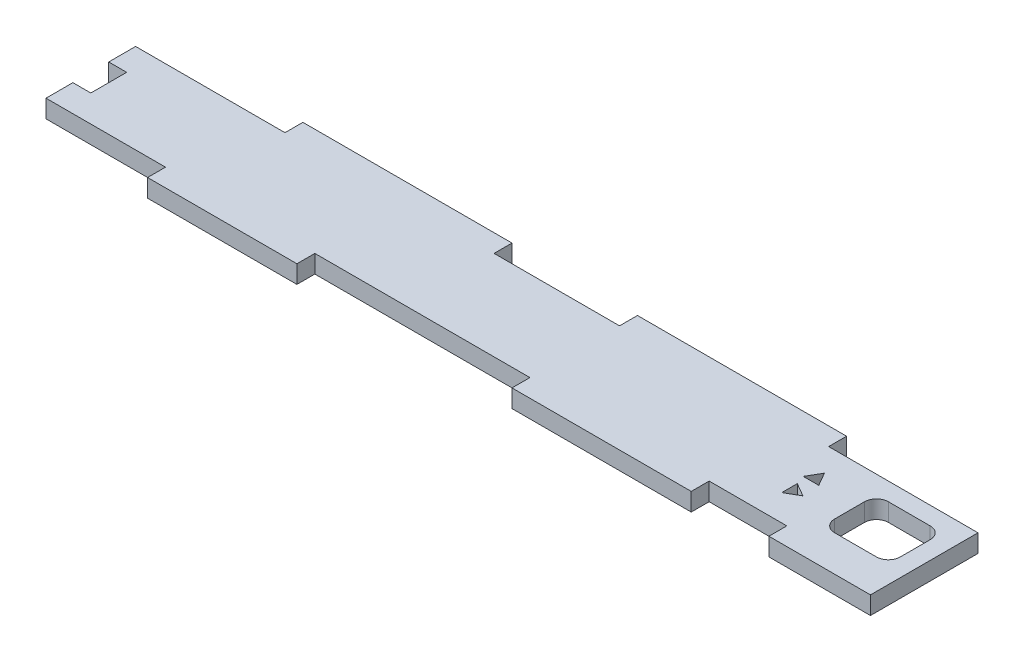
from build123d import *

# Parameters (mm, degrees)
SKETCH1_W                = 141
SKETCH1_H                = 15
BOSS_EXTRUDE1_DEPTH      = 1.5
SKETCH2_W                = 30
SKETCH2_H                = 3
SKETCH2_W_2              = 17
BOSS_EXTRUDE2_DEPTH      = 1.5
SKETCH12_W               = 25
SKETCH12_H               = 3
BOSS_EXTRUDE3_DEPTH      = 1.5
SKETCH13_W               = 35
SKETCH13_H               = 3
BOSS_EXTRUDE4_DEPTH      = 1.5
SKETCH15_W               = 11
SKETCH15_H               = 9
CUT_EXTRUDE10_DEPTH      = 2.5
CUT_EXTRUDE10_DEPTH_BACK = 2.5
FILLET4_R                = 2
CUT_EXTRUDE11_DEPTH      = 2.5
CUT_EXTRUDE11_DEPTH_BACK = 2.5
SKETCH17_W               = 3
SKETCH17_H               = 6
CUT_EXTRUDE12_DEPTH      = 2.5
CUT_EXTRUDE12_DEPTH_BACK = 2.5


with BuildPart() as part:
    # Sketch1 → Boss-Extrude1 (new body, symmetric)
    with BuildSketch(Plane(origin=(0, 0, 0), x_dir=(1, 0, 0), z_dir=(0, 1, 0))):
        Rectangle(SKETCH1_W, SKETCH1_H)
    extrude(amount=BOSS_EXTRUDE1_DEPTH, both=True)

    # Sketch2 → Boss-Extrude2 (add, symmetric)
    with BuildSketch(Plane(origin=(0, 0, 0), x_dir=(1, 0, 0), z_dir=(0, 1, 0))):
        with Locations((25.5, -9)):
            Rectangle(SKETCH2_W, SKETCH2_H)
        with Locations((62, -9)):
            Rectangle(SKETCH2_W_2, SKETCH2_H)
    extrude(amount=BOSS_EXTRUDE2_DEPTH, both=True)

    # Sketch12 → Boss-Extrude3 (add, symmetric)
    with BuildSketch(Plane(origin=(0, 0, 0), x_dir=(1, 0, 0), z_dir=(0, 1, 0))):
        with Locations((-38, -9)):
            Rectangle(SKETCH12_W, SKETCH12_H)
    extrude(amount=BOSS_EXTRUDE3_DEPTH, both=True)

    # Sketch13 → Boss-Extrude4 (add, symmetric)
    with BuildSketch(Plane(origin=(0, 0, 0), x_dir=(1, 0, 0), z_dir=(0, 1, 0))):
        with Locations((-28, 9)):
            Rectangle(SKETCH13_W, SKETCH13_H)
        with Locations((28, 9)):
            Rectangle(SKETCH13_W, SKETCH13_H)
    extrude(amount=BOSS_EXTRUDE4_DEPTH, both=True)

    # Sketch15 → Cut-Extrude10 (cut, two sides)
    with BuildSketch(Plane(origin=(0, 0, 0), x_dir=(1, 0, 0), z_dir=(0, 1, 0))) as cut_extrude10_sk:
        with Locations((62, 0)):
            Rectangle(SKETCH15_W, SKETCH15_H)
    extrude(amount=CUT_EXTRUDE10_DEPTH, mode=Mode.SUBTRACT)
    extrude(cut_extrude10_sk.sketch, amount=-CUT_EXTRUDE10_DEPTH_BACK, mode=Mode.SUBTRACT)

    # Fillet4
    fillet4_edges = [part.edges().sort_by_distance(p)[0] for p in [
        (56.5, 0, 4.5),
        (56.5, 0, -4.5),
        (67.5, 0, -4.5),
        (67.5, 0, 4.5),
    ]]
    fillet(fillet4_edges, radius=FILLET4_R)

    # Sketch16 → Cut-Extrude11 (cut, two sides)
    with BuildSketch(Plane(origin=(0, 0, 0), x_dir=(1, 0, 0), z_dir=(0, 1, 0))) as cut_extrude11_sk:
        Polygon((49, 3.299038106), (47.700961894, 1.049038106), (50.299038106, 1.049038106), align=None)
        Polygon((50.5, -1.799038106), (48.25, -0.5), (48.25, -3.098076211), align=None)
    extrude(amount=CUT_EXTRUDE11_DEPTH, mode=Mode.SUBTRACT)
    extrude(cut_extrude11_sk.sketch, amount=-CUT_EXTRUDE11_DEPTH_BACK, mode=Mode.SUBTRACT)

    # Sketch17 → Cut-Extrude12 (cut, two sides)
    with BuildSketch(Plane(origin=(0, 0, 0), x_dir=(1, 0, 0), z_dir=(0, 1, 0))) as cut_extrude12_sk:
        with Locations((-69, 0)):
            Rectangle(SKETCH17_W, SKETCH17_H)
    extrude(amount=CUT_EXTRUDE12_DEPTH, mode=Mode.SUBTRACT)
    extrude(cut_extrude12_sk.sketch, amount=-CUT_EXTRUDE12_DEPTH_BACK, mode=Mode.SUBTRACT)


solid = part.part
